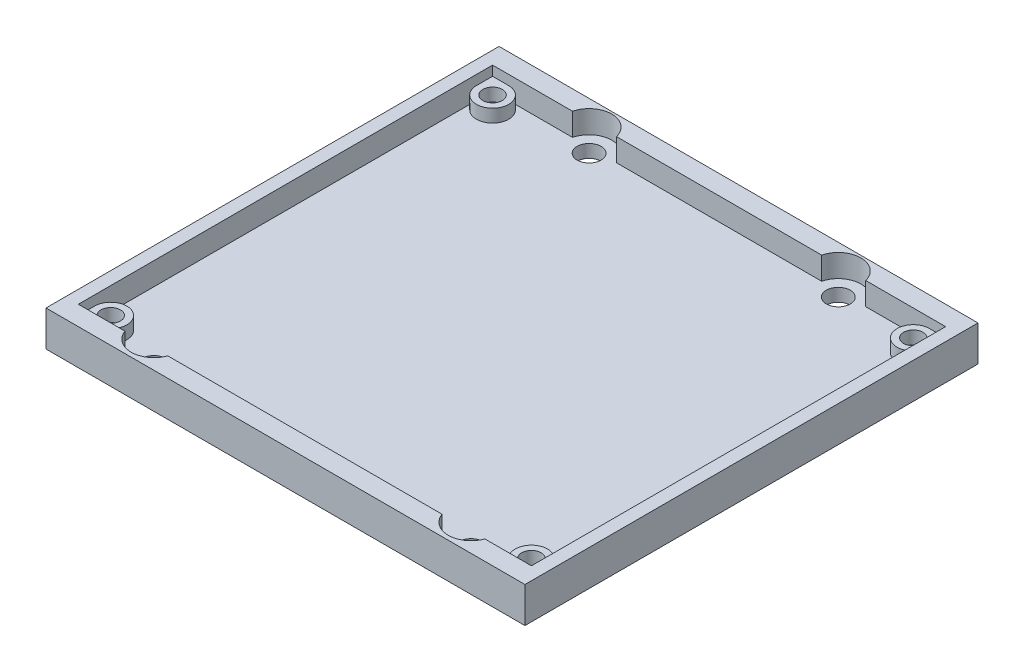
from build123d import *

# Parameters (mm, degrees)
SKETCH1_R           = 1.85
BOSS_EXTRUDE1_DEPTH = 2
SKETCH2_W           = 74
SKETCH2_H           = 70
SKETCH2_R           = 1.5
BOSS_EXTRUDE2_DEPTH = 2
SKETCH3_W           = 74
SKETCH3_H           = 70
BOSS_EXTRUDE3_DEPTH = 1.5


with BuildPart() as part:
    # Sketch1 → Boss-Extrude1 (new body)
    with BuildSketch(Plane(origin=(0, 0, 0), x_dir=(1, 0, 0), z_dir=(0, 1, 0))):
        Polygon((0, 0), (74, 0), (74, 70), (56.753344727, 70), (55.746655273, 70), (18.253344727, 70), (17.246655273, 70), (0, 70), align=None)
        with Locations((17.75, 66.160760925)):
            Circle(SKETCH1_R, mode=Mode.SUBTRACT)
        with Locations((12.5, 4.160760925)):
            Circle(SKETCH1_R, mode=Mode.SUBTRACT)
        with Locations((61.5, 4.160760925)):
            Circle(SKETCH1_R, mode=Mode.SUBTRACT)
        with Locations((56.25, 66.160760925)):
            Circle(SKETCH1_R, mode=Mode.SUBTRACT)
    extrude(amount=BOSS_EXTRUDE1_DEPTH)

    # Sketch2 → Boss-Extrude2 (add)
    with BuildSketch(Plane(origin=(0, 2, 0), x_dir=(1, 0, 0), z_dir=(0, 1, 0))):
        with Locations((37, 35)):
            Rectangle(SKETCH2_W, SKETCH2_H)
        with Locations((4.5, 5.5)):
            Circle(SKETCH2_R, mode=Mode.SUBTRACT)
        with Locations((69.5, 5.5)):
            Circle(SKETCH2_R, mode=Mode.SUBTRACT)
        with Locations((69.5, 64.5)):
            Circle(SKETCH2_R, mode=Mode.SUBTRACT)
        with Locations((4.5, 64.5)):
            Circle(SKETCH2_R, mode=Mode.SUBTRACT)
        with BuildLine():
            Line((4.5, 3), (9.198086301, 3))
            ThreePointArc((9.198086301, 3), (12.5, 0.660760925), (15.801913699, 3))
            Line((15.801913699, 3), (58.198086301, 3))
            ThreePointArc((58.198086301, 3), (61.5, 0.660760925), (64.801913699, 3))
            Line((64.801913699, 3), (69.5, 3))
            ThreePointArc((69.5, 3), (67.732233047, 7.267766953), (72, 5.5))
            Line((72, 5.5), (72, 64.5))
            ThreePointArc((72, 64.5), (67.732233047, 62.732233047), (69.5, 67))
            Line((69.5, 67), (59.647893138, 67))
            ThreePointArc((59.647893138, 67), (56.25, 69.660760925), (52.852106862, 67))
            Line((52.852106862, 67), (21.147893138, 67))
            ThreePointArc((21.147893138, 67), (17.75, 69.660760925), (14.352106862, 67))
            Line((14.352106862, 67), (4.5, 67))
            ThreePointArc((4.5, 67), (6.267766953, 62.732233047), (2, 64.5))
            Line((2, 64.5), (2, 5.5))
            ThreePointArc((2, 5.5), (6.267766953, 7.267766953), (4.5, 3))
        make_face(mode=Mode.SUBTRACT)
    extrude(amount=BOSS_EXTRUDE2_DEPTH)

    # Sketch3 → Boss-Extrude3 (add)
    with BuildSketch(Plane(origin=(0, 4, 0), x_dir=(1, 0, 0), z_dir=(0, 1, 0))):
        with Locations((37, 35)):
            Rectangle(SKETCH3_W, SKETCH3_H)
        with BuildLine():
            Line((9.198086301, 3), (2, 3))
            Line((2, 3), (2, 67))
            Line((2, 67), (4.5, 67))
            Line((4.5, 67), (14.352106862, 67))
            ThreePointArc((14.352106862, 67), (17.75, 69.660760925), (21.147893138, 67))
            Line((21.147893138, 67), (52.852106862, 67))
            ThreePointArc((52.852106862, 67), (56.25, 69.660760925), (59.647893138, 67))
            Line((59.647893138, 67), (72, 67))
            Line((72, 67), (72, 64.6))
            Line((72, 64.6), (72, 3))
            Line((72, 3), (64.801913699, 3))
            ThreePointArc((64.801913699, 3), (61.5, 0.660760925), (58.198086301, 3))
            Line((58.198086301, 3), (15.801913699, 3))
            ThreePointArc((15.801913699, 3), (12.5, 0.660760925), (9.198086301, 3))
        make_face(mode=Mode.SUBTRACT)
    extrude(amount=BOSS_EXTRUDE3_DEPTH)


solid = part.part
